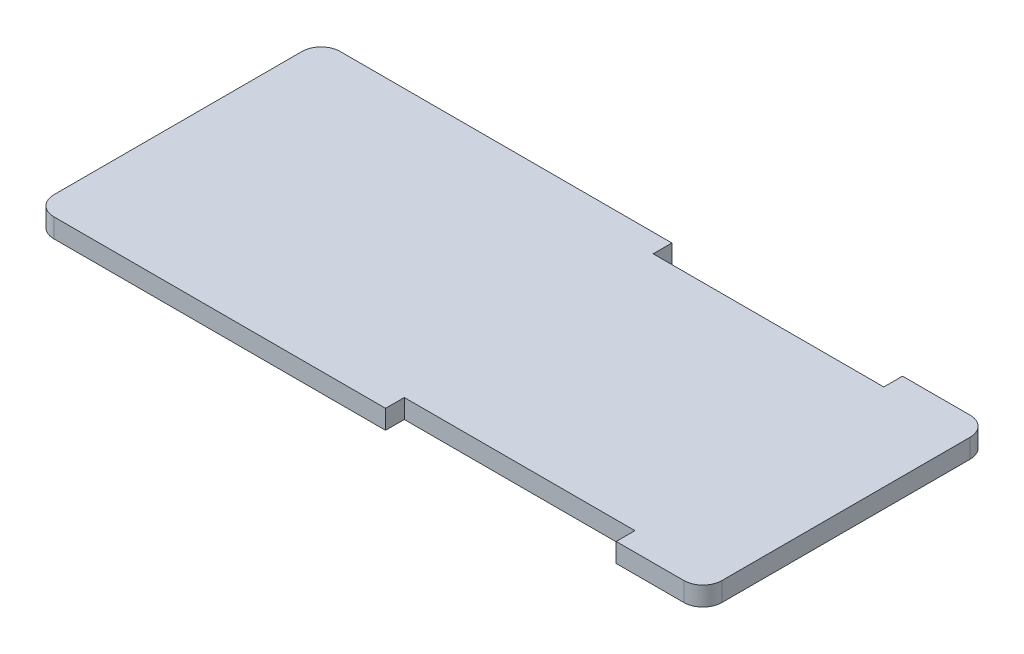
from build123d import *

# Parameters (mm, degrees)
SKETCH1_W           = 350
SKETCH1_H           = 150
BOSS_EXTRUDE1_DEPTH = 10
FILLET2_R           = 10
SKETCH9_W           = 120.821087965
SKETCH9_H           = 9.816766212
CUT_EXTRUDE6_DEPTH  = 25


with BuildPart() as part:
    # Sketch1 → Boss-Extrude1 (new body)
    with BuildSketch(Plane(origin=(0, 0, 0), x_dir=(1, 0, 0), z_dir=(0, 1, 0))):
        with Locations((175, -75)):
            Rectangle(SKETCH1_W, SKETCH1_H)
    extrude(amount=BOSS_EXTRUDE1_DEPTH)

    # Fillet2
    fillet2_edges = [part.edges().sort_by_distance(p)[0] for p in [
        (0, 5, 0),
        (350, 5, 0),
        (350, 5, 150),
        (0, 5, 150),
    ]]
    fillet(fillet2_edges, radius=FILLET2_R)

    # Sketch9 → Cut-Extrude6 (cut)
    with BuildSketch(Plane(origin=(0, 10, 0), x_dir=(1, 0, 0), z_dir=(0, 1, 0))):
        with Locations((244.170878002, -145.091616894)):
            Rectangle(SKETCH9_W, SKETCH9_H)
        with Locations((244.170878002, -4.908383106)):
            Rectangle(SKETCH9_W, SKETCH9_H)
    extrude(amount=-CUT_EXTRUDE6_DEPTH, mode=Mode.SUBTRACT)


solid = part.part
